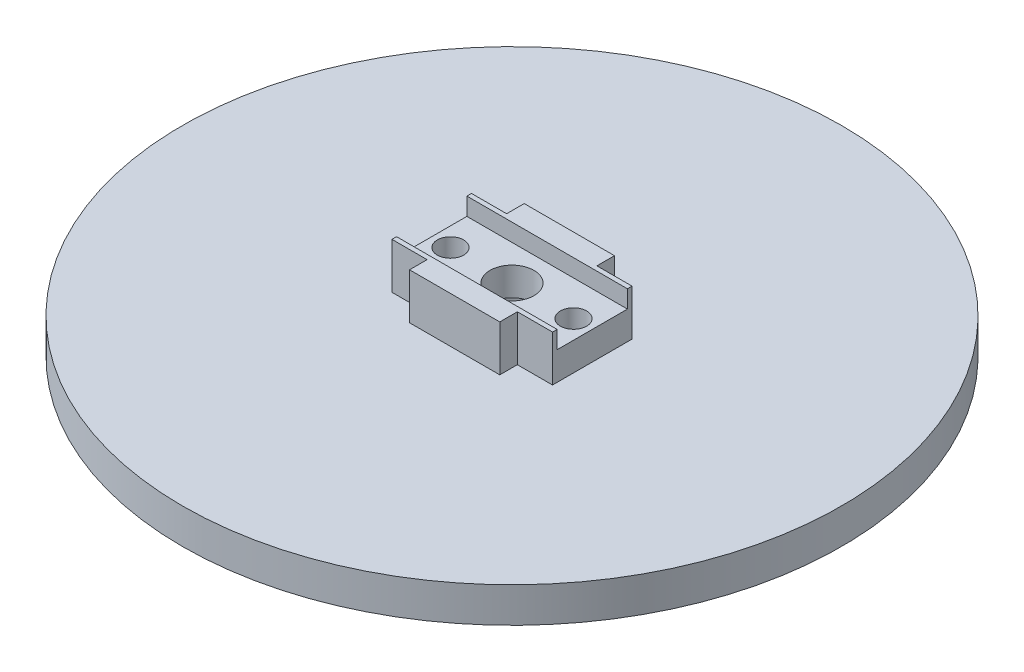
from build123d import *

# Parameters (mm, degrees)
SKETCH1_R           = 37.5
BOSS_EXTRUDE1_DEPTH = 4
SKETCH2_R           = 5.22
CUT_EXTRUDE1_DEPTH  = 13.05
SKETCH3_W           = 18.27
SKETCH3_H           = 13.05
BOSS_EXTRUDE2_DEPTH = 5.22
SKETCH4_W           = 4
SKETCH4_H           = 2
CUT_EXTRUDE2_DEPTH  = 5.22
SKETCH5_W           = 53.664550202
SKETCH5_H           = 8
CUT_EXTRUDE3_DEPTH  = 2
SKETCH6_R           = 1.5
CUT_EXTRUDE4_DEPTH  = 4
SKETCH7_R           = 2.5
CUT_EXTRUDE5_DEPTH  = 8.22


with BuildPart() as part:
    # Sketch1 → Boss-Extrude1 (new body)
    with BuildSketch(Plane(origin=(0, 0, 0), x_dir=(1, 0, 0), z_dir=(0, 1, 0))):
        Circle(SKETCH1_R)
    extrude(amount=BOSS_EXTRUDE1_DEPTH)

    # Sketch2 → Cut-Extrude1 (cut)
    with BuildSketch(Plane(origin=(0, 4, 0), x_dir=(1, 0, 0), z_dir=(0, 1, 0))):
        Circle(SKETCH2_R)
    extrude(amount=-CUT_EXTRUDE1_DEPTH, mode=Mode.SUBTRACT)

    # Sketch3 → Boss-Extrude2 (add)
    with BuildSketch(Plane(origin=(0, 4, 0), x_dir=(1, 0, 0), z_dir=(0, 1, 0))):
        Rectangle(SKETCH3_W, SKETCH3_H)
    extrude(amount=BOSS_EXTRUDE2_DEPTH)

    # Sketch4 → Cut-Extrude2 (cut)
    with BuildSketch(Plane(origin=(0, 9.22, 0), x_dir=(1, 0, 0), z_dir=(0, 1, 0))):
        with Locations((-7.135, -5.525)):
            Rectangle(SKETCH4_W, SKETCH4_H)
        with Locations((-7.135, 5.525)):
            Rectangle(SKETCH4_W, SKETCH4_H)
        with Locations((7.135, 5.525)):
            Rectangle(SKETCH4_W, SKETCH4_H)
        with Locations((7.135, -5.525)):
            Rectangle(SKETCH4_W, SKETCH4_H)
    extrude(amount=-CUT_EXTRUDE2_DEPTH, mode=Mode.SUBTRACT)

    # Sketch5 → Cut-Extrude3 (cut)
    with BuildSketch(Plane(origin=(0, 9.22, 0), x_dir=(1, 0, 0), z_dir=(0, 1, 0))):
        Rectangle(SKETCH5_W, SKETCH5_H)
    extrude(amount=-CUT_EXTRUDE3_DEPTH, mode=Mode.SUBTRACT)

    # Sketch6 → Cut-Extrude4 (cut)
    with BuildSketch(Plane(origin=(0, 7.22, 0), x_dir=(1, 0, 0), z_dir=(0, 1, 0))):
        with Locations((-7, 0)):
            Circle(SKETCH6_R)
        with Locations((7, 0)):
            Circle(SKETCH6_R)
    extrude(amount=-CUT_EXTRUDE4_DEPTH, mode=Mode.SUBTRACT)

    # Sketch7 → Cut-Extrude5 (cut, through all)
    with BuildSketch(Plane(origin=(0, 7.22, 0), x_dir=(1, 0, 0), z_dir=(0, 1, 0))):
        Circle(SKETCH7_R)
    extrude(amount=-CUT_EXTRUDE5_DEPTH, mode=Mode.SUBTRACT)


solid = part.part
